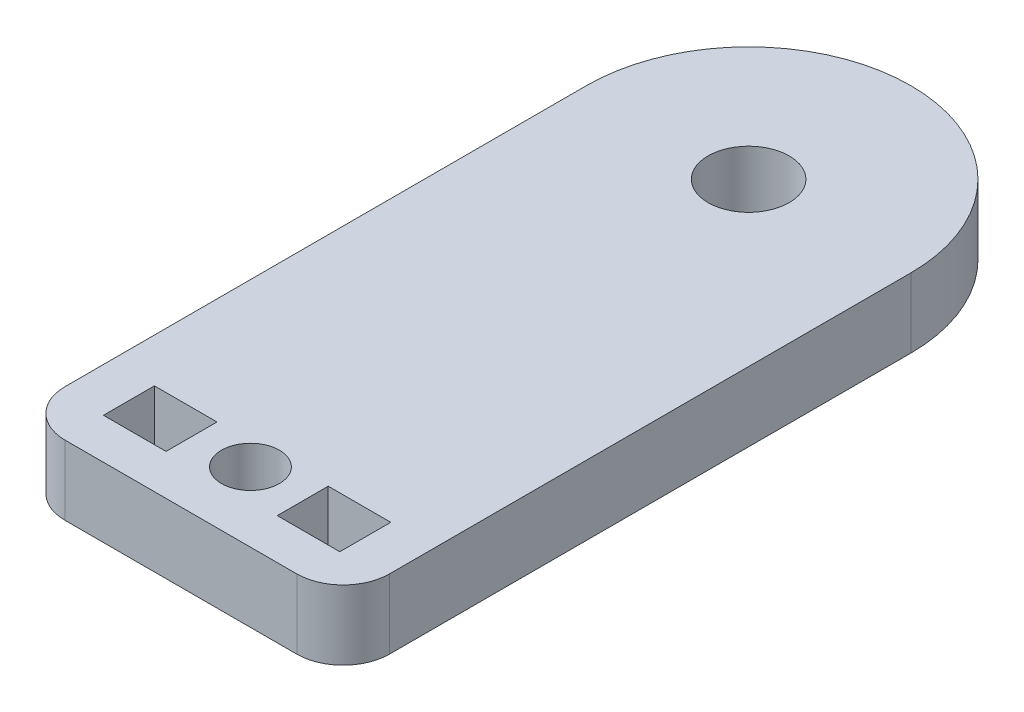
from build123d import *

# Parameters (mm, degrees)
SKETCH_1_W      = 2.7
SKETCH_1_H      = 2.2
SKETCH_1_R      = 1.25
SKETCH_1_R_2    = 1.75
EXTRUDE_1_DEPTH = 3


with BuildPart() as part:
    # 草图1 → 凸台-拉伸1 (new body)
    with BuildSketch(Plane(origin=(0, 0, 0), x_dir=(1, 0, 0), z_dir=(0, 1, 0))):
        with BuildLine():
            ThreePointArc((-7, -10.25), (-6.414213562, -11.664213562), (-5, -12.25))
            Line((-5, -12.25), (5, -12.25))
            ThreePointArc((5, -12.25), (6.414213562, -11.664213562), (7, -10.25))
            Line((7, -10.25), (7, 12.25))
            ThreePointArc((7, 12.25), (0, 19.25), (-7, 12.25))
            Line((-7, 12.25), (-7, -10.25))
        make_face()
        with Locations((-3.75, -9.393390946)):
            Rectangle(SKETCH_1_W, SKETCH_1_H, mode=Mode.SUBTRACT)
        with Locations((0, -9.25)):
            Circle(SKETCH_1_R, mode=Mode.SUBTRACT)
        with Locations((3.75, -9.393390946)):
            Rectangle(SKETCH_1_W, SKETCH_1_H, mode=Mode.SUBTRACT)
        with Locations((0, 12.25)):
            Circle(SKETCH_1_R_2, mode=Mode.SUBTRACT)
    extrude(amount=EXTRUDE_1_DEPTH)


solid = part.part
